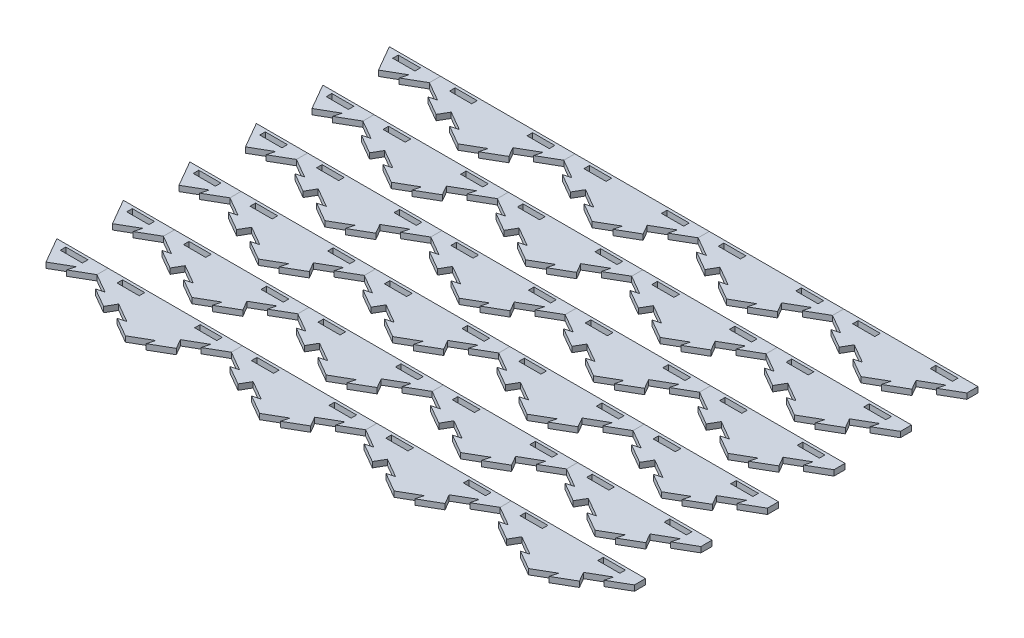
from build123d import *

# Parameters (mm, degrees)
BOSS_EXTRUDE1_DEPTH = 6.35
CUT_EXTRUDE4_DEPTH  = 155.110195964
BOSS_EXTRUDE4_DEPTH = 6.35
CIRPATTERN1_COUNT   = 2
CIRPATTERN1_ANGLE   = 60
SKETCH12_W          = 153.979316792
SKETCH12_H          = 120.65
CUT_EXTRUDE5_DEPTH  = 155.110195964
SKETCH13_W          = 25.4
SKETCH13_H          = 6.35
CUT_EXTRUDE6_DEPTH  = 90.126497182
LPATTERN1_COUNT     = 5
LPATTERN1_PITCH     = 153.979316882
LPATTERN1_2_COUNT   = 2
LPATTERN1_2_PITCH   = 153.979316882
SKETCH14_W          = 25.4
SKETCH14_H          = 6.35
SKETCH14_W_2        = 76.989658396
SKETCH14_H_2        = 57.15
CUT_EXTRUDE7_DEPTH  = 695.360232872
SKETCH15_W          = 58.658787349
SKETCH15_H          = 40.424261314
CUT_EXTRUDE8_DEPTH  = 600.270912242
LPATTERN2_COUNT     = 6
LPATTERN2_PITCH     = 76.2


with BuildPart() as part:
    # Sketch1 → Boss-Extrude1 (new body)
    with BuildSketch(Plane(origin=(0, 0, 0), x_dir=(1, 0, 0), z_dir=(0, 1, 0))):
        Polygon((-76.989658396, 0), (0, -44.45), (76.989658396, 0), (76.989658396, 88.9), (0, 133.35), (-76.989658396, 88.9), align=None)
    extrude(amount=-BOSS_EXTRUDE1_DEPTH)

    # Sketch10 → Cut-Extrude4 (cut, through all)
    with BuildSketch(Plane(origin=(0, 0, 0), x_dir=(1, 0, 0), z_dir=(0, 1, 0))):
        Polygon((-21.997045256, -31.75), (-13.322783942, -29.425738686), (-35.319829198, -16.725738686), (-38.494829198, -22.225), align=None)
    cut_extrude4 = extrude(amount=-CUT_EXTRUDE4_DEPTH, mode=Mode.SUBTRACT)

    # Sketch11 → Boss-Extrude4 (add)
    with BuildSketch(Plane(origin=(0, 0, 0), x_dir=(1, 0, 0), z_dir=(0, 1, 0))):
        Polygon((-38.494829198, -22.225), (-41.669829198, -27.724261314), (-63.666874454, -15.024261314), (-54.99261314, -12.7), align=None)
    boss_extrude4 = extrude(amount=-BOSS_EXTRUDE4_DEPTH)

    # CirPattern1: Cut-Extrude4, Boss-Extrude4 ×2 about axis
    cirpattern1_axis = Axis((0, 0, -44.45), (0, 1, 0))
    add([cut_extrude4.rotate(cirpattern1_axis, i * CIRPATTERN1_ANGLE / (CIRPATTERN1_COUNT - 1)) for i in range(1, CIRPATTERN1_COUNT)], mode=Mode.SUBTRACT)
    add([boss_extrude4.rotate(cirpattern1_axis, i * CIRPATTERN1_ANGLE / (CIRPATTERN1_COUNT - 1)) for i in range(1, CIRPATTERN1_COUNT)])

    # Sketch12 → Cut-Extrude5 (cut, through all)
    with BuildSketch(Plane(origin=(0, 0, 0), x_dir=(1, 0, 0), z_dir=(0, 1, 0))):
        with Locations((0, 73.025)):
            Rectangle(SKETCH12_W, SKETCH12_H)
    extrude(amount=-CUT_EXTRUDE5_DEPTH, mode=Mode.SUBTRACT)

    # Sketch13 → Cut-Extrude6 (cut, through all)
    with BuildSketch(Plane(origin=(0, 0, 0), x_dir=(1, 0, 0), z_dir=(0, 1, 0))):
        with Locations((-44.45, 6.35)):
            Rectangle(SKETCH13_W, SKETCH13_H)
        with Locations((44.45, 6.35)):
            Rectangle(SKETCH13_W, SKETCH13_H)
    extrude(amount=-CUT_EXTRUDE6_DEPTH, mode=Mode.SUBTRACT)


with BuildPart() as lpattern1_1:
    # LPattern1: pattern copy
    add(part.part.moved(Location(Vector(1, 0, 0) * (1 * LPATTERN1_PITCH))))


with BuildPart() as lpattern1_2:
    # LPattern1: pattern copy
    add(part.part.moved(Location(Vector(1, 0, 0) * (2 * LPATTERN1_PITCH))))


with BuildPart() as lpattern1_3:
    # LPattern1: pattern copy
    add(part.part.moved(Location(Vector(1, 0, 0) * (3 * LPATTERN1_PITCH))))


with BuildPart() as lpattern1_4:
    # LPattern1: pattern copy
    add(part.part.moved(Location(Vector(1, 0, 0) * (4 * LPATTERN1_PITCH))))


with BuildPart() as lpattern1_2_1:
    # LPattern1 2: pattern copy
    add(part.part.moved(Location(Vector(-1, 0, 0) * (1 * LPATTERN1_2_PITCH))))


with BuildPart() as cut_extrude7_tool:
    # Sketch14 → Cut-Extrude7 (new, through all)
    # profile 1 of 4: a face of its own
    with BuildSketch(Plane(origin=(0, 0, 0), x_dir=(1, 0, 0), z_dir=(0, 1, 0))):
        Polygon((-134.30653294, -40.424261314), (-153.979316882, -44.45), (-153.979316882, 12.7), (-135.648445835, 12.7), (-112.309487684, -27.724261314), align=None)
    # profile 2 of 4: a face of its own
    with BuildSketch(Plane(origin=(0, 0, 0), x_dir=(1, 0, 0), z_dir=(0, 1, 0))):
        Polygon((593.920222272, -31.75), (615.917267528, -44.45), (615.917267528, 12.7), (597.586396481, 12.7), (580.59743833, -16.725738686), (602.594483586, -29.425738686), align=None)
    # profile 3 of 4: a face of its own
    with BuildSketch(Plane(origin=(0, 0, 0), x_dir=(1, 0, 0), z_dir=(0, 1, 0))):
        Polygon((615.917267528, 12.7), (615.917267528, -44.45), (637.914312784, -31.75), (635.59005147, -40.424261314), (657.587096726, -27.724261314), (651.237096726, -16.725738686), (673.234141982, -4.025738686), (670.909880668, -12.7), (692.906925924, 0), (692.906925924, 12.7), align=None)
        with Locations((660.367267528, 6.35)):
            Rectangle(SKETCH14_W, SKETCH14_H, mode=Mode.SUBTRACT)
    # profile 4 of 4: a face of its own
    with BuildSketch(Plane(origin=(0, 0, 0), x_dir=(1, 0, 0), z_dir=(0, 1, 0))):
        with Locations((-192.47414608, -15.875)):
            Rectangle(SKETCH14_W_2, SKETCH14_H_2)
    extrude(amount=-CUT_EXTRUDE7_DEPTH)


with BuildPart() as lpattern1_4_1:
    add(lpattern1_4.part)

    # Cut-Extrude7: cut by cut_extrude7_tool
    add(cut_extrude7_tool.part, mode=Mode.SUBTRACT)

    # Sketch15 → Cut-Extrude8 (cut, through all)
    with BuildSketch(Plane(origin=(0, 0, 0), x_dir=(1, 0, 0), z_dir=(0, 1, 0))):
        with Locations((568.257002807, -7.512130657)):
            Rectangle(SKETCH15_W, SKETCH15_H)
    extrude(amount=-CUT_EXTRUDE8_DEPTH, mode=Mode.SUBTRACT)


with BuildPart() as lpattern1_2_1_1:
    add(lpattern1_2_1.part)

    # Cut-Extrude7: cut by cut_extrude7_tool
    add(cut_extrude7_tool.part, mode=Mode.SUBTRACT)


with BuildPart() as lpattern2_1:
    # LPattern2: pattern copy
    add(lpattern1_3.part.moved(Location(Vector(0, 0, 1) * (1 * LPATTERN2_PITCH))))


with BuildPart() as lpattern2_2:
    # LPattern2: pattern copy
    add(lpattern1_3.part.moved(Location(Vector(0, 0, 1) * (2 * LPATTERN2_PITCH))))


with BuildPart() as lpattern2_3:
    # LPattern2: pattern copy
    add(lpattern1_3.part.moved(Location(Vector(0, 0, 1) * (3 * LPATTERN2_PITCH))))


with BuildPart() as lpattern2_4:
    # LPattern2: pattern copy
    add(lpattern1_3.part.moved(Location(Vector(0, 0, 1) * (4 * LPATTERN2_PITCH))))


with BuildPart() as lpattern2_5:
    # LPattern2: pattern copy
    add(lpattern1_3.part.moved(Location(Vector(0, 0, 1) * (5 * LPATTERN2_PITCH))))


with BuildPart() as lpattern2_6:
    # LPattern2: pattern copy
    add(lpattern1_2.part.moved(Location(Vector(0, 0, 1) * (1 * LPATTERN2_PITCH))))


with BuildPart() as lpattern2_7:
    # LPattern2: pattern copy
    add(lpattern1_2.part.moved(Location(Vector(0, 0, 1) * (2 * LPATTERN2_PITCH))))


with BuildPart() as lpattern2_8:
    # LPattern2: pattern copy
    add(lpattern1_2.part.moved(Location(Vector(0, 0, 1) * (3 * LPATTERN2_PITCH))))


with BuildPart() as lpattern2_9:
    # LPattern2: pattern copy
    add(lpattern1_2.part.moved(Location(Vector(0, 0, 1) * (4 * LPATTERN2_PITCH))))


with BuildPart() as lpattern2_10:
    # LPattern2: pattern copy
    add(lpattern1_2.part.moved(Location(Vector(0, 0, 1) * (5 * LPATTERN2_PITCH))))


with BuildPart() as lpattern2_11:
    # LPattern2: pattern copy
    add(lpattern1_1.part.moved(Location(Vector(0, 0, 1) * (1 * LPATTERN2_PITCH))))


with BuildPart() as lpattern2_12:
    # LPattern2: pattern copy
    add(lpattern1_1.part.moved(Location(Vector(0, 0, 1) * (2 * LPATTERN2_PITCH))))


with BuildPart() as lpattern2_13:
    # LPattern2: pattern copy
    add(lpattern1_1.part.moved(Location(Vector(0, 0, 1) * (3 * LPATTERN2_PITCH))))


with BuildPart() as lpattern2_14:
    # LPattern2: pattern copy
    add(lpattern1_1.part.moved(Location(Vector(0, 0, 1) * (4 * LPATTERN2_PITCH))))


with BuildPart() as lpattern2_15:
    # LPattern2: pattern copy
    add(lpattern1_1.part.moved(Location(Vector(0, 0, 1) * (5 * LPATTERN2_PITCH))))


with BuildPart() as lpattern2_16:
    # LPattern2: pattern copy
    add(part.part.moved(Location(Vector(0, 0, 1) * (1 * LPATTERN2_PITCH))))


with BuildPart() as lpattern2_17:
    # LPattern2: pattern copy
    add(part.part.moved(Location(Vector(0, 0, 1) * (2 * LPATTERN2_PITCH))))


with BuildPart() as lpattern2_18:
    # LPattern2: pattern copy
    add(part.part.moved(Location(Vector(0, 0, 1) * (3 * LPATTERN2_PITCH))))


with BuildPart() as lpattern2_19:
    # LPattern2: pattern copy
    add(part.part.moved(Location(Vector(0, 0, 1) * (4 * LPATTERN2_PITCH))))


with BuildPart() as lpattern2_20:
    # LPattern2: pattern copy
    add(part.part.moved(Location(Vector(0, 0, 1) * (5 * LPATTERN2_PITCH))))


with BuildPart() as lpattern2_21:
    # LPattern2: pattern copy
    add(lpattern1_2_1_1.part.moved(Location(Vector(0, 0, 1) * (1 * LPATTERN2_PITCH))))


with BuildPart() as lpattern2_22:
    # LPattern2: pattern copy
    add(lpattern1_2_1_1.part.moved(Location(Vector(0, 0, 1) * (2 * LPATTERN2_PITCH))))


with BuildPart() as lpattern2_23:
    # LPattern2: pattern copy
    add(lpattern1_2_1_1.part.moved(Location(Vector(0, 0, 1) * (3 * LPATTERN2_PITCH))))


with BuildPart() as lpattern2_24:
    # LPattern2: pattern copy
    add(lpattern1_2_1_1.part.moved(Location(Vector(0, 0, 1) * (4 * LPATTERN2_PITCH))))


with BuildPart() as lpattern2_25:
    # LPattern2: pattern copy
    add(lpattern1_2_1_1.part.moved(Location(Vector(0, 0, 1) * (5 * LPATTERN2_PITCH))))


solid = Compound([part.part, lpattern1_1.part, lpattern1_2.part, lpattern1_3.part, lpattern1_2_1_1.part, lpattern2_1.part, lpattern2_2.part, lpattern2_3.part, lpattern2_4.part, lpattern2_5.part, lpattern2_6.part, lpattern2_7.part, lpattern2_8.part, lpattern2_9.part, lpattern2_10.part, lpattern2_11.part, lpattern2_12.part, lpattern2_13.part, lpattern2_14.part, lpattern2_15.part, lpattern2_16.part, lpattern2_17.part, lpattern2_18.part, lpattern2_19.part, lpattern2_20.part, lpattern2_21.part, lpattern2_22.part, lpattern2_23.part, lpattern2_24.part, lpattern2_25.part])
